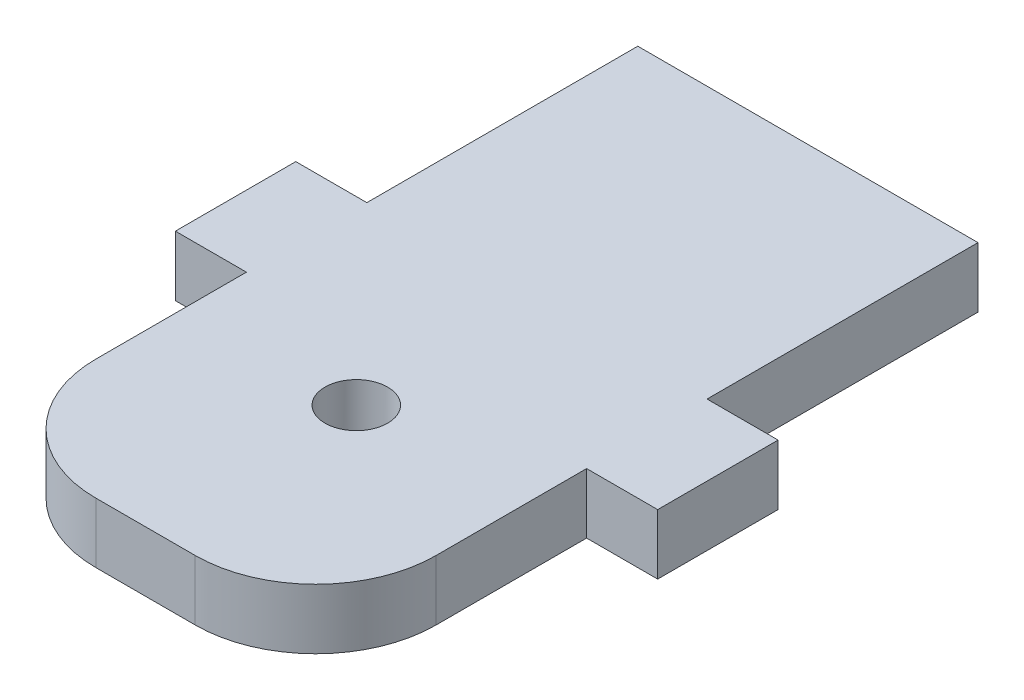
from build123d import *

# Parameters (mm, degrees)
SKETCH1_W           = 28.25
SKETCH1_H           = 55
BOSS_EXTRUDE1_DEPTH = 5
SKETCH3_W           = 5.9
SKETCH3_H           = 10
BOSS_EXTRUDE2_DEPTH = 5
SKETCH2_R           = 2.6
CUT_EXTRUDE1_DEPTH  = 10
FILLET1_R           = 10


with BuildPart() as part:
    # Sketch1 → Boss-Extrude1 (new body)
    with BuildSketch(Plane(origin=(0, 0, 0), x_dir=(1, 0, 0), z_dir=(0, 1, 0))):
        Rectangle(SKETCH1_W, SKETCH1_H)
    extrude(amount=BOSS_EXTRUDE1_DEPTH)

    # Sketch3 → Boss-Extrude2 (add)
    with BuildSketch(Plane(origin=(0, 5, 0), x_dir=(1, 0, 0), z_dir=(0, 1, 0))):
        with Locations((-17.075, 0)):
            Rectangle(SKETCH3_W, SKETCH3_H)
        with Locations((17.075, 0)):
            Rectangle(SKETCH3_W, SKETCH3_H)
    extrude(amount=-BOSS_EXTRUDE2_DEPTH)

    # Sketch2 → Cut-Extrude1 (cut)
    with BuildSketch(Plane(origin=(0, 5, 0), x_dir=(1, 0, 0), z_dir=(0, 1, 0))):
        with Locations((0, -10)):
            Circle(SKETCH2_R)
    extrude(amount=-CUT_EXTRUDE1_DEPTH, mode=Mode.SUBTRACT)

    # Fillet1
    fillet1_edges = [part.edges().sort_by_distance(p)[0] for p in [
        (14.125, 2.5, 27.5),
        (-14.125, 2.5, 27.5),
    ]]
    fillet(fillet1_edges, radius=FILLET1_R)


solid = part.part
